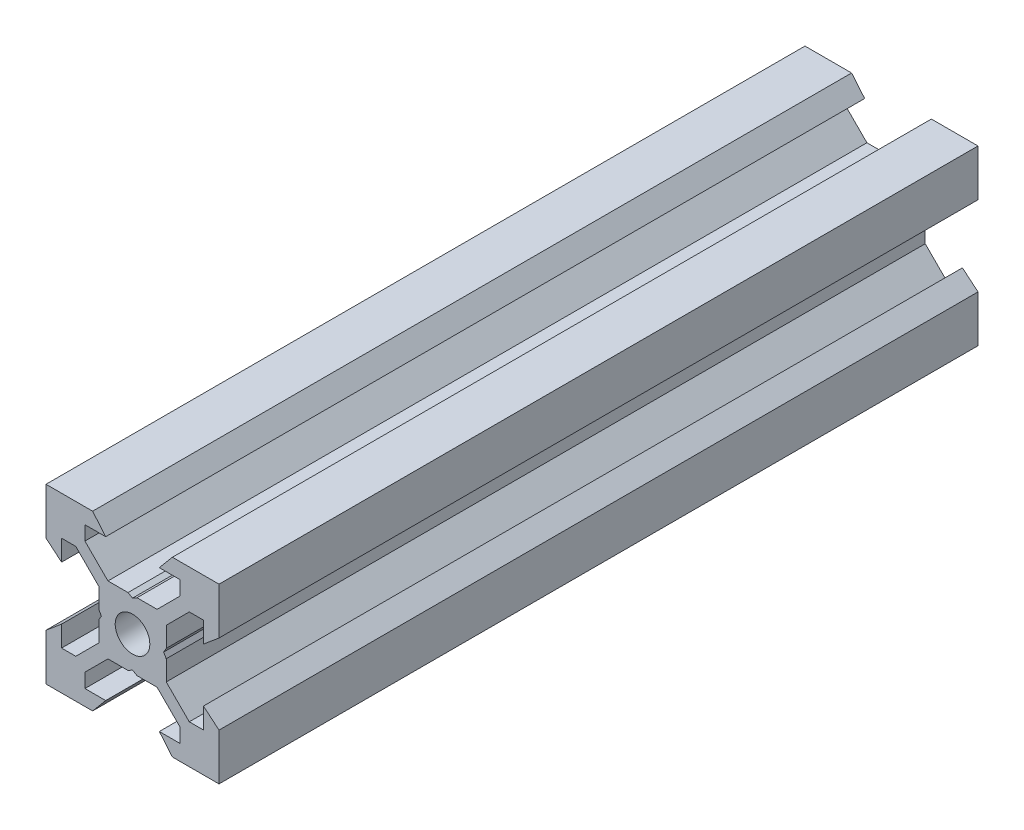
from build123d import *

# Parameters (mm, degrees)
SKETCH1_R           = 2
BOSS_EXTRUDE1_DEPTH = 43.865


with BuildPart() as part:
    # Sketch1 → Boss-Extrude1 (new body, symmetric)
    with BuildSketch(Plane.XY):
        Polygon((10, 10), (10, 4.610379336), (8.2, 3.1), (8.2, 5.5), (6.560660172, 5.5), (3.9, 2.839339828), (3.9, 0.519615242), (3.6, 0), (3.9, -0.519615242), (3.9, -2.839339828), (6.560660172, -5.5), (8.2, -5.5), (8.2, -3.1), (10, -4.610379336), (10, -10), (4.610379336, -10), (3.1, -8.2), (5.5, -8.2), (5.5, -6.560660172), (2.839339828, -3.9), (0.519615242, -3.9), (0, -3.6), (-0.519615242, -3.9), (-2.839339828, -3.9), (-5.5, -6.560660172), (-5.5, -8.2), (-3.1, -8.2), (-4.610379336, -10), (-10, -10), (-10, -4.610379336), (-8.2, -3.1), (-8.2, -5.5), (-6.560660172, -5.5), (-3.9, -2.839339828), (-3.9, -0.519615242), (-3.6, 0), (-3.9, 0.519615242), (-3.9, 2.839339828), (-6.560660172, 5.5), (-8.2, 5.5), (-8.2, 3.1), (-10, 4.610379336), (-10, 10), (-4.610379336, 10), (-3.1, 8.2), (-5.5, 8.2), (-5.5, 6.560660172), (-2.839339828, 3.9), (-0.519615242, 3.9), (0, 3.6), (0.519615242, 3.9), (2.839339828, 3.9), (5.5, 6.560660172), (5.5, 8.2), (3.1, 8.2), (4.610379336, 10), align=None)
        Circle(SKETCH1_R, mode=Mode.SUBTRACT)
    extrude(amount=BOSS_EXTRUDE1_DEPTH, both=True)


solid = part.part
